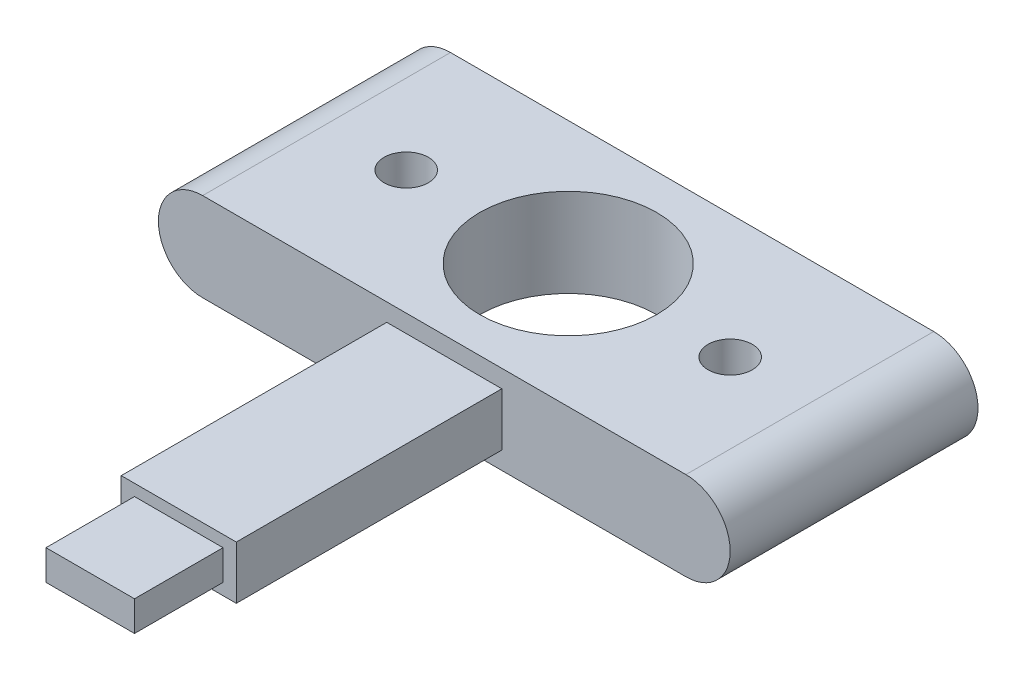
from build123d import *

# Parameters (mm, degrees)
BOSS_EXTRUDE1_DEPTH = 35.56
SKETCH2_W           = 16.51
SKETCH2_H           = 38.1
BOSS_EXTRUDE2_DEPTH = 12.7
SKETCH3_W           = 38.1
SKETCH3_H           = 2.54
CUT_EXTRUDE1_DEPTH  = 50.276
SKETCH4_W           = 12.7
SKETCH4_H           = 4.318
BOSS_EXTRUDE3_DEPTH = 12.7
SKETCH5_R           = 12.7
CUT_EXTRUDE2_DEPTH  = 13.7
SKETCH6_R           = 3.175
CUT_EXTRUDE3_DEPTH  = 5.08


with BuildPart() as part:
    # Sketch1 → Boss-Extrude1 (new body)
    with BuildSketch(Plane.XY):
        with BuildLine():
            ThreePointArc((0, 6.35), (1.859871939, 1.859871939), (6.35, 0))
            Line((6.35, 0), (75.692, 0))
            ThreePointArc((75.692, 0), (80.182128061, 1.859871939), (82.042, 6.35))
            ThreePointArc((82.042, 6.35), (80.182128061, 10.840128061), (75.692, 12.7))
            Line((75.692, 12.7), (6.35, 12.7))
            ThreePointArc((6.35, 12.7), (1.859871939, 10.840128061), (0, 6.35))
        make_face()
    extrude(amount=BOSS_EXTRUDE1_DEPTH)

    # Sketch2 → Boss-Extrude2 (add)
    with BuildSketch(Plane(origin=(0, 12.7, 0), x_dir=(1, 0, 0), z_dir=(0, 1, 0))):
        with Locations((41.021, -54.61)):
            Rectangle(SKETCH2_W, SKETCH2_H)
    extrude(amount=-BOSS_EXTRUDE2_DEPTH)

    # Sketch3 → Cut-Extrude1 (cut, through all)
    with BuildSketch(Plane.ZY.offset(-32.766)):
        with Locations((54.61, 11.43)):
            Rectangle(SKETCH3_W, SKETCH3_H)
        with Locations((54.61, 1.27)):
            Rectangle(SKETCH3_W, SKETCH3_H)
    extrude(amount=-CUT_EXTRUDE1_DEPTH, mode=Mode.SUBTRACT)

    # Sketch4 → Boss-Extrude3 (add)
    with BuildSketch(Plane.XY.offset(73.66)):
        with Locations((41.021, 6.35)):
            Rectangle(SKETCH4_W, SKETCH4_H)
    extrude(amount=BOSS_EXTRUDE3_DEPTH)

    # Sketch5 → Cut-Extrude2 (cut, through all)
    with BuildSketch(Plane(origin=(0, 12.7, 0), x_dir=(1, 0, 0), z_dir=(0, 1, 0))):
        with Locations((41.021, -17.78)):
            Circle(SKETCH5_R)
    extrude(amount=-CUT_EXTRUDE2_DEPTH, mode=Mode.SUBTRACT)

    # Sketch6 → Cut-Extrude3 (cut)
    with BuildSketch(Plane(origin=(0, 12.7, 0), x_dir=(1, 0, 0), z_dir=(0, 1, 0))):
        with Locations((64.262, -17.78)):
            Circle(SKETCH6_R)
        with Locations((17.78, -17.78)):
            Circle(SKETCH6_R)
    extrude(amount=-CUT_EXTRUDE3_DEPTH, mode=Mode.SUBTRACT)


solid = part.part
